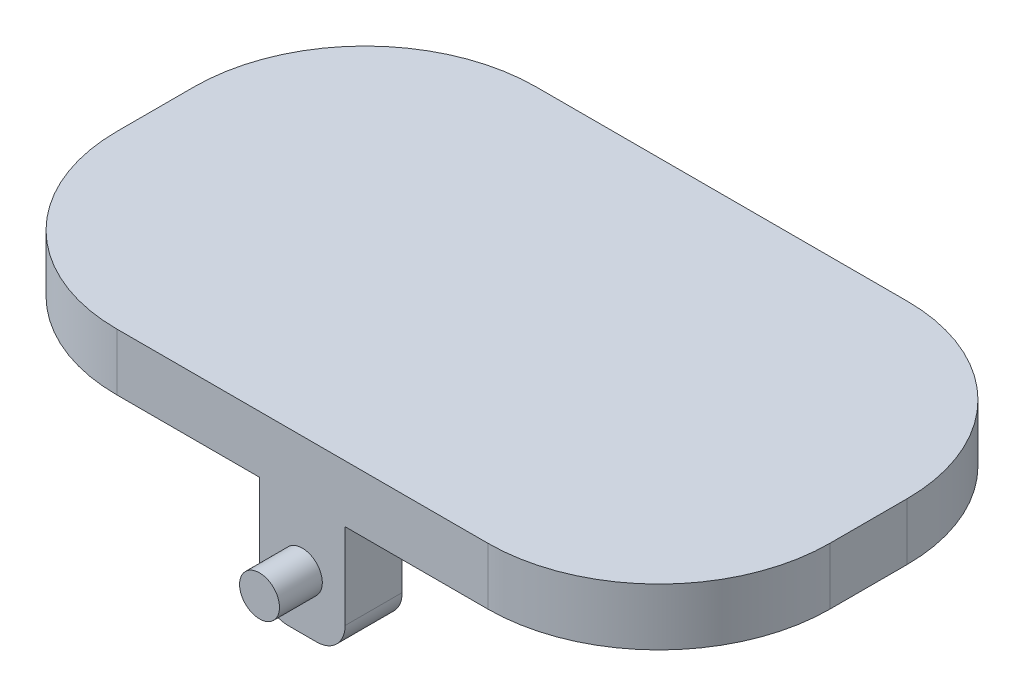
from build123d import *

# Parameters (mm, degrees)
SKETCH1_W           = 25
SKETCH1_H           = 14.7
BOSS_EXTRUDE1_DEPTH = 2
FILLET1_R           = 6
BOSS_EXTRUDE6_DEPTH = 2
SKETCH5_R           = 0.7
BOSS_EXTRUDE7_DEPTH = 1.5


with BuildPart() as part:
    # Sketch1 → Boss-Extrude1 (new body)
    with BuildSketch(Plane(origin=(0, 0, 0), x_dir=(1, 0, 0), z_dir=(0, 1, 0))):
        Rectangle(SKETCH1_W, SKETCH1_H)
    extrude(amount=BOSS_EXTRUDE1_DEPTH)

    # Fillet1
    fillet1_edges = [part.edges().sort_by_distance(p)[0] for p in [
        (12.5, 1, 7.35),
        (-12.5, 1, 7.35),
        (-12.5, 1, -7.35),
        (12.5, 1, -7.35),
    ]]
    fillet(fillet1_edges, radius=FILLET1_R)

    # Sketch3 → Boss-Extrude6 (add)
    with BuildSketch(Plane(origin=(0, 0, -7.35), x_dir=(-1, 0, 0), z_dir=(0, 0, -1))):
        with BuildLine():
            Line((-1.5, 0), (-1.5, -3))
            ThreePointArc((-1.5, -3), (-1.207106781, -3.707106781), (-0.5, -4))
            Line((-0.5, -4), (0.5, -4))
            ThreePointArc((0.5, -4), (1.207106781, -3.707106781), (1.5, -3))
            Line((1.5, -3), (1.5, 0))
            Line((1.5, 0), (-1.5, 0))
        make_face()
    boss_extrude6 = extrude(amount=-BOSS_EXTRUDE6_DEPTH)

    # Sketch5 → Boss-Extrude7 (add)
    with BuildSketch(Plane(origin=(0, 0, -7.35), x_dir=(-1, 0, 0), z_dir=(0, 0, -1))):
        with Locations(Location((0, -2.1, 0), (0, 0, 180))):  # turned: the seam where the file's is
            Circle(SKETCH5_R)
    boss_extrude7 = extrude(amount=BOSS_EXTRUDE7_DEPTH)

    # Mirror3: Boss-Extrude6, Boss-Extrude7 across plane
    add(boss_extrude6.mirror(Plane.XY))
    add(boss_extrude7.mirror(Plane.XY))


solid = part.part
